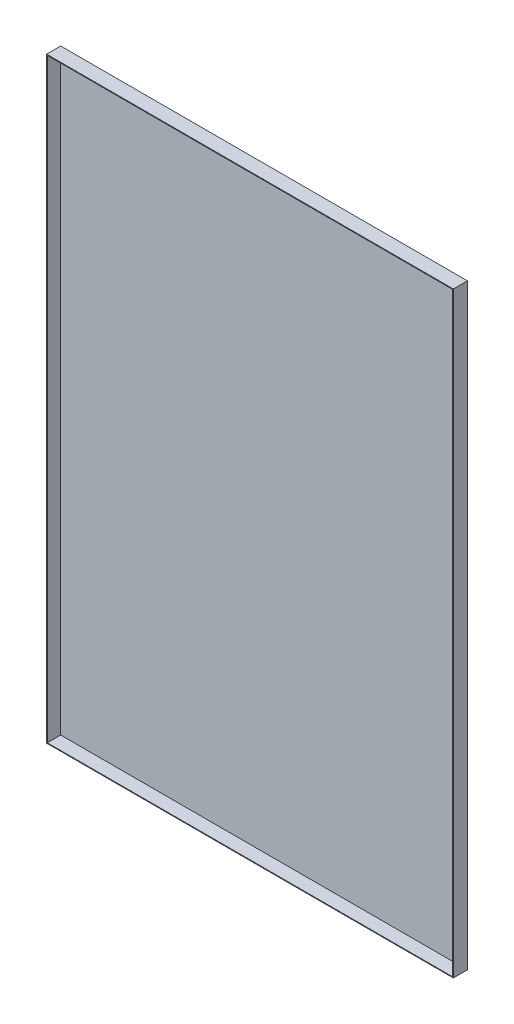
from build123d import *

# Parameters (mm, degrees)
SKETCH_1_W      = 578
SKETCH_1_H      = 848
EXTRUDE_1_DEPTH = 20
SHELL_1_T       = -1


with BuildPart() as part:
    # 草图1 → 凸台-拉伸1 (new body)
    with BuildSketch(Plane.XY):
        Rectangle(SKETCH_1_W, SKETCH_1_H)
    extrude(amount=EXTRUDE_1_DEPTH)

    # 抽壳1
    shell_1_openings = [part.faces().sort_by_distance(p)[0] for p in [
        (0, 0, 20),
    ]]
    offset(amount=SHELL_1_T, openings=shell_1_openings, kind=Kind.INTERSECTION)


solid = part.part
